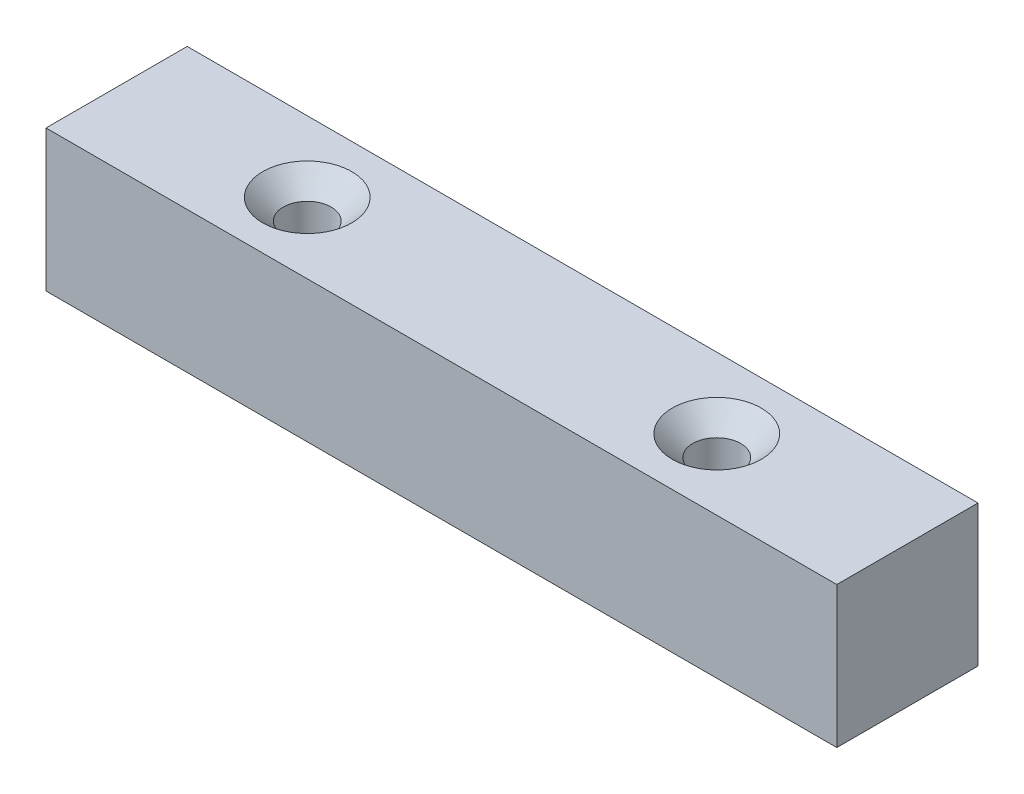
from build123d import *

# Parameters (mm, degrees)
SKETCH1_W                                       = 56
SKETCH1_H                                       = 10
BOSS_EXTRUDE1_DEPTH                             = 10
CSK_FOR_M3_FLAT_HEAD_MACHINE_SCREW1_D           = 3.4
CSK_FOR_M3_FLAT_HEAD_MACHINE_SCREW1_CSINK_D     = 6.3
CSK_FOR_M3_FLAT_HEAD_MACHINE_SCREW1_CSINK_ANGLE = 90
F_5_0MM_DOWEL_HOLE1_D                           = 5
F_5_0MM_DOWEL_HOLE1_DEPTH                       = 5
F_5_0MM_DOWEL_HOLE1_TIP                         = 1.502151548


with BuildPart() as part:
    # Sketch1 → Boss-Extrude1 (new body)
    with BuildSketch(Plane(origin=(0, 0, 0), x_dir=(1, 0, 0), z_dir=(0, 1, 0))):
        with Locations((0.542682927, 11.422256098)):
            Rectangle(SKETCH1_W, SKETCH1_H)
    extrude(amount=BOSS_EXTRUDE1_DEPTH)

    # CSK for M3 Flat Head Machine Screw1 (through all)
    with Locations(Plane(origin=(0, 10, 0), x_dir=(1, 0, 0), z_dir=(0, 1, 0))):
        with Locations((15.042682927, 11.422256098), (-13.957317073, 11.422256098)):
            CounterSinkHole(CSK_FOR_M3_FLAT_HEAD_MACHINE_SCREW1_D / 2, CSK_FOR_M3_FLAT_HEAD_MACHINE_SCREW1_CSINK_D / 2, counter_sink_angle=CSK_FOR_M3_FLAT_HEAD_MACHINE_SCREW1_CSINK_ANGLE)

    # Ø5.0mm Dowel Hole1
    with Locations(Plane(origin=(0, 0, 0), x_dir=(-1, 0, 0), z_dir=(0, -1, 0))):
        with Locations((22.457317073, 11.422256098), (-23.542682927, 11.422256098)):
            Hole(F_5_0MM_DOWEL_HOLE1_D / 2, depth=F_5_0MM_DOWEL_HOLE1_DEPTH)
            with Locations((0, 0, -(F_5_0MM_DOWEL_HOLE1_DEPTH + F_5_0MM_DOWEL_HOLE1_TIP / 2))):  # 118° drill point
                Cone(0, F_5_0MM_DOWEL_HOLE1_D / 2, F_5_0MM_DOWEL_HOLE1_TIP, mode=Mode.SUBTRACT)


solid = part.part
